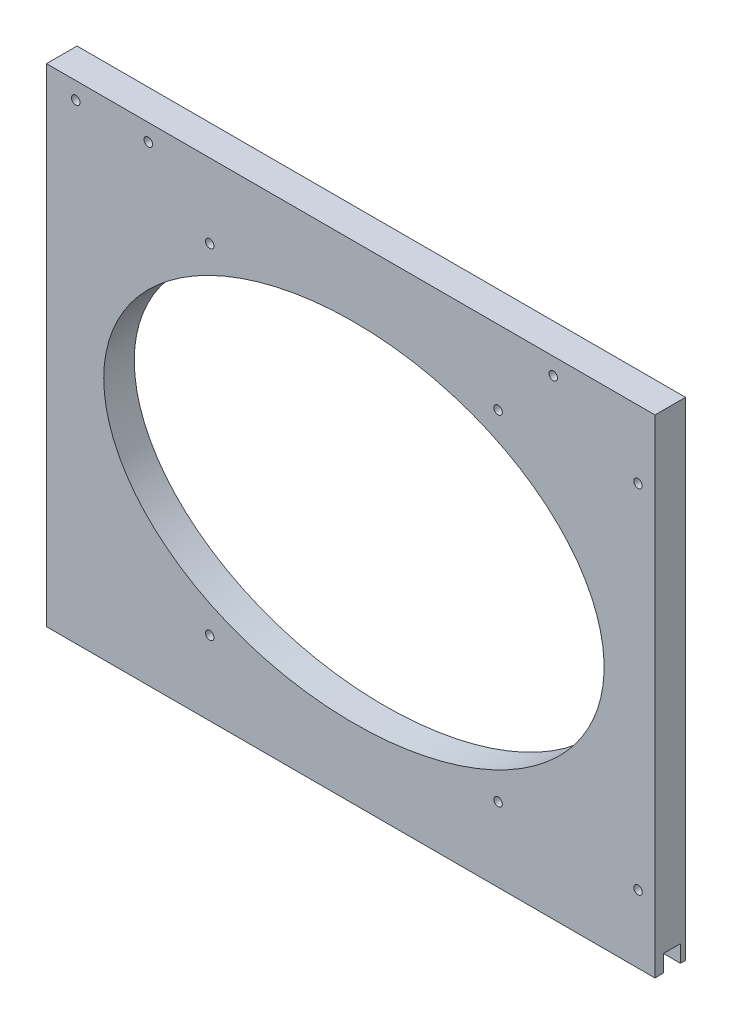
from build123d import *

# Parameters (mm, degrees)
SPEAKERPANEL_W               = 227.80625
SPEAKERPANEL_H               = 182.5625
SPEAKERPANEL_THICKNESS_DEPTH = 11.43
SKETCH3_R                    = 1.5875
SKETCH3_RX                   = 93.6625
SKETCH3_RY                   = 65.087499997
SPEAKERCUTOUT_DEPTH          = 11.43
SPEAKERSLOTSCREEN_DEPTH      = 227.80625
SKETCH5_R                    = 1.5875
CUT_EXTRUDE1_DEPTH           = 11.43


with BuildPart() as part:
    # SpeakerPanel → SpeakerPanel_Thickness (new body)
    with BuildSketch(Plane.XY):
        with Locations((-5372.496875, 1089.81875)):
            Rectangle(SPEAKERPANEL_W, SPEAKERPANEL_H)
    extrude(amount=-SPEAKERPANEL_THICKNESS_DEPTH)

    # Sketch3 → SpeakerCutout (cut)
    with BuildSketch(Plane.XY):
        with Locations((-5448.3, 1174.75)):
            Circle(SKETCH3_R)
        with Locations((-5425.28125, 1153.31875)):
            Circle(SKETCH3_R)
        with Locations((-5296.69375, 1174.75)):
            Circle(SKETCH3_R)
        with Locations((-5317.33125, 1153.31875)):
            Circle(SKETCH3_R)
        with Locations((-5264.94375, 1155.7)):
            Circle(SKETCH3_R)
        with Locations((-5264.94375, 1023.9375)):
            Circle(SKETCH3_R)
        with Locations((-5317.33125, 1026.31875)):
            Circle(SKETCH3_R)
        with Locations((-5425.28125, 1026.31875)):
            Circle(SKETCH3_R)
        with Locations(Location((-5371.30625, 1089.81875), (0, 0, 180))):
            Ellipse(SKETCH3_RX, SKETCH3_RY)
    extrude(amount=-SPEAKERCUTOUT_DEPTH, mode=Mode.SUBTRACT)

    # Sketch4 → SpeakerSlotScreen (cut)
    with BuildSketch(Plane(origin=(-5258.59375, 0, 0), x_dir=(0, 0, -1), z_dir=(1, 0, 0))):
        Polygon((5.715, 998.5375), (3.175, 998.5375), (3.175, 1004.8875), (9.525, 1004.8875), (9.525, 998.5375), align=None)
    extrude(amount=-SPEAKERSLOTSCREEN_DEPTH, mode=Mode.SUBTRACT)

    # Sketch5 → Cut-Extrude1 (cut)
    with BuildSketch(Plane(origin=(0, 0, -11.43), x_dir=(-1, 0, 0), z_dir=(0, 0, -1))):
        with Locations((5475.43355, 1174.75)):
            Circle(SKETCH5_R)
    extrude(amount=-CUT_EXTRUDE1_DEPTH, mode=Mode.SUBTRACT)


solid = part.part
